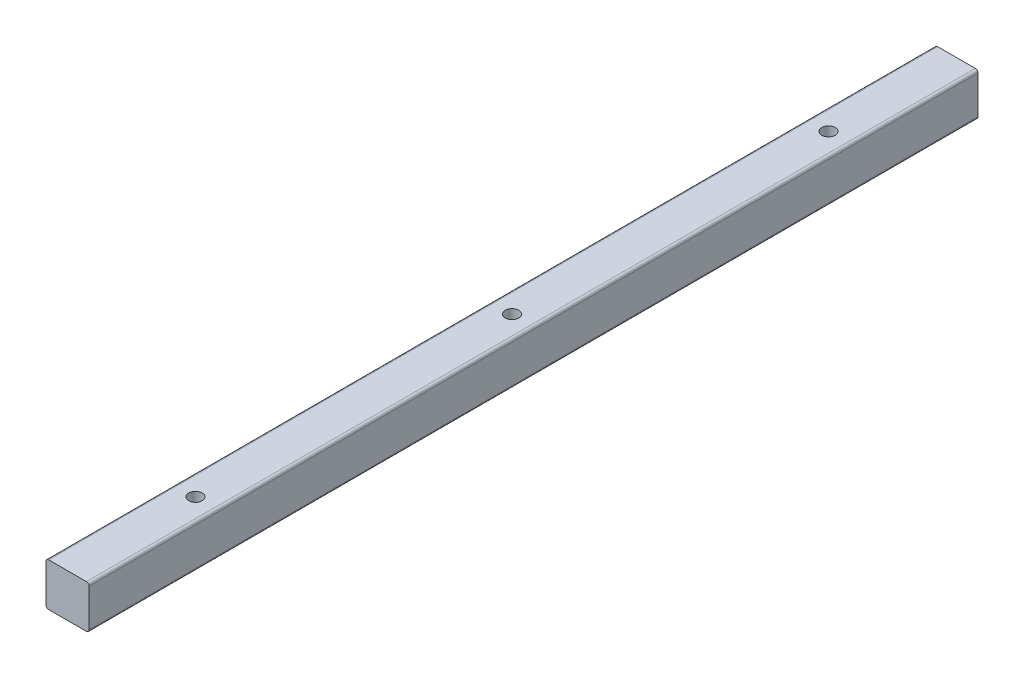
from build123d import *

# Parameters (mm, degrees)
BOSS_EXTRU_1_DEPTH    = 165
TROU_TARAUD_M61_D     = 5
TROU_TARAUD_M61_DEPTH = 13
TROU_TARAUD_M61_TIP   = 1.502151548
TROU_TARAUD_M31_D     = 2.5
TROU_TARAUD_M31_DEPTH = 8.5
TROU_TARAUD_M31_TIP   = 0.751075774


with BuildPart() as part:
    # Esquisse1 → Boss.-Extru.1 (new body, symmetric)
    with BuildSketch(Plane.XY):
        with BuildLine():
            Line((7, 8), (-7, 8))
            ThreePointArc((-7, 8), (-7.707106781, 7.707106781), (-8, 7))
            Line((-8, 7), (-8, -7))
            ThreePointArc((-8, -7), (-7.707106781, -7.707106781), (-7, -8))
            Line((-7, -8), (7, -8))
            ThreePointArc((7, -8), (7.707106781, -7.707106781), (8, -7))
            Line((8, -7), (8, 7))
            ThreePointArc((8, 7), (7.707106781, 7.707106781), (7, 8))
        make_face()
    extrude(amount=BOSS_EXTRU_1_DEPTH, both=True)

    # Trou taraudé M61
    with Locations(Plane(origin=(0, 8, 0), x_dir=(1, 0, 0), z_dir=(0, 1, 0))):
        with Locations((0, 0), (0, 117.5), (0, -117.5)):
            Hole(TROU_TARAUD_M61_D / 2, depth=TROU_TARAUD_M61_DEPTH)
            with Locations((0, 0, -(TROU_TARAUD_M61_DEPTH + TROU_TARAUD_M61_TIP / 2))):  # 118° drill point
                Cone(0, TROU_TARAUD_M61_D / 2, TROU_TARAUD_M61_TIP, mode=Mode.SUBTRACT)

    # Trou taraudé M31
    with Locations(Plane(origin=(0, -8, 0), x_dir=(-1, 0, 0), z_dir=(0, -1, 0))):
        with Locations((0, 10), (0, 50)):
            Hole(TROU_TARAUD_M31_D / 2, depth=TROU_TARAUD_M31_DEPTH)
            with Locations((0, 0, -(TROU_TARAUD_M31_DEPTH + TROU_TARAUD_M31_TIP / 2))):  # 118° drill point
                Cone(0, TROU_TARAUD_M31_D / 2, TROU_TARAUD_M31_TIP, mode=Mode.SUBTRACT)


solid = part.part
